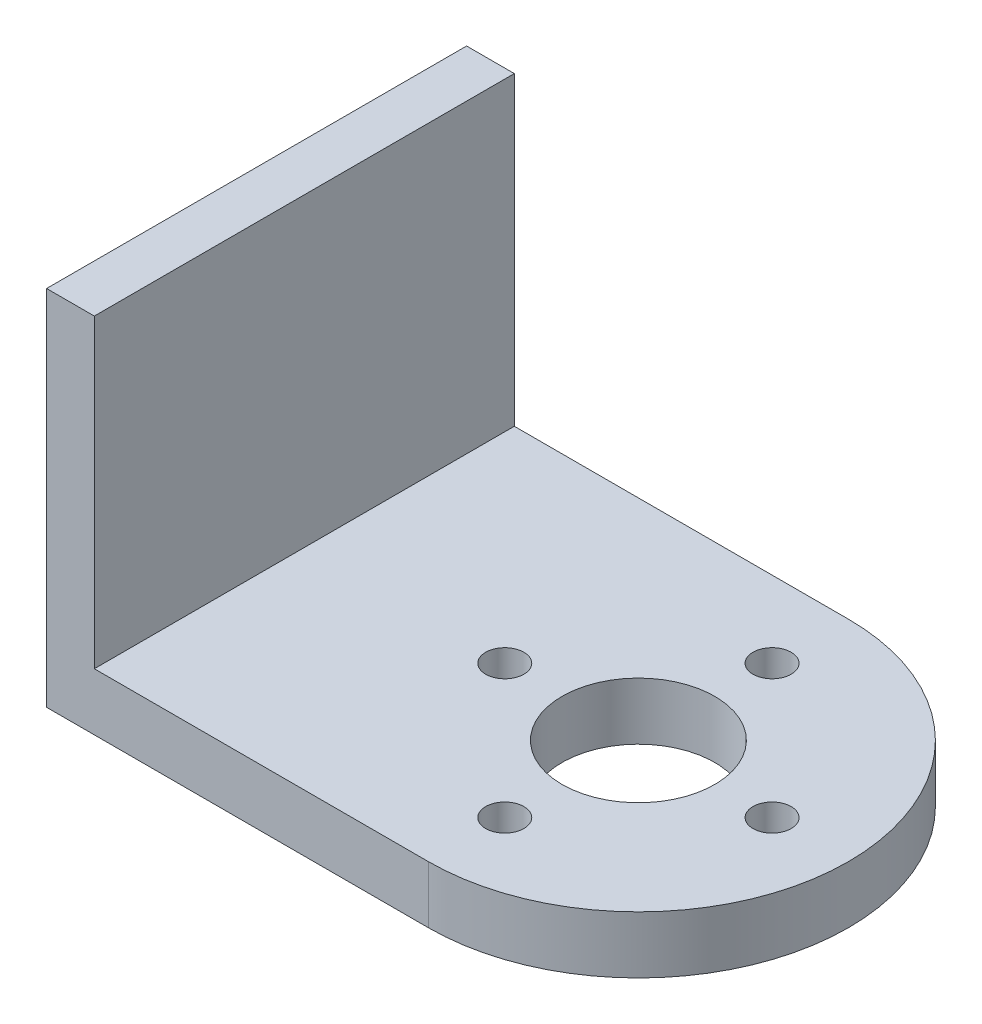
from build123d import *

# Parameters (mm, degrees)
SKETCH1_R           = 1
SKETCH1_R_2         = 4
BOSS_EXTRUDE1_DEPTH = 3
SKETCH2_W           = 2.5
SKETCH2_H           = 22
BOSS_EXTRUDE2_DEPTH = 16


with BuildPart() as part:
    # Sketch1 → Boss-Extrude1 (new body)
    with BuildSketch(Plane(origin=(0, 0, 0), x_dir=(1, 0, 0), z_dir=(0, 1, 0))):
        with BuildLine():
            Line((-14, -11), (-14, 11))
            Line((-14, 11), (6, 11))
            ThreePointArc((6, 11), (17, 0), (6, -11))
            Line((6, -11), (-14, -11))
        make_face()
        with Locations((6, -7)):
            Circle(SKETCH1_R, mode=Mode.SUBTRACT)
        with Locations((-1, 0)):
            Circle(SKETCH1_R, mode=Mode.SUBTRACT)
        with Locations((6, 0)):
            Circle(SKETCH1_R_2, mode=Mode.SUBTRACT)
        with Locations((13, 0)):
            Circle(SKETCH1_R, mode=Mode.SUBTRACT)
        with Locations((6, 7)):
            Circle(SKETCH1_R, mode=Mode.SUBTRACT)
    extrude(amount=BOSS_EXTRUDE1_DEPTH)

    # Sketch2 → Boss-Extrude2 (add)
    with BuildSketch(Plane(origin=(0, 3, 0), x_dir=(1, 0, 0), z_dir=(0, 1, 0))):
        with Locations((-12.75, 0)):
            Rectangle(SKETCH2_W, SKETCH2_H)
    extrude(amount=BOSS_EXTRUDE2_DEPTH)


solid = part.part
